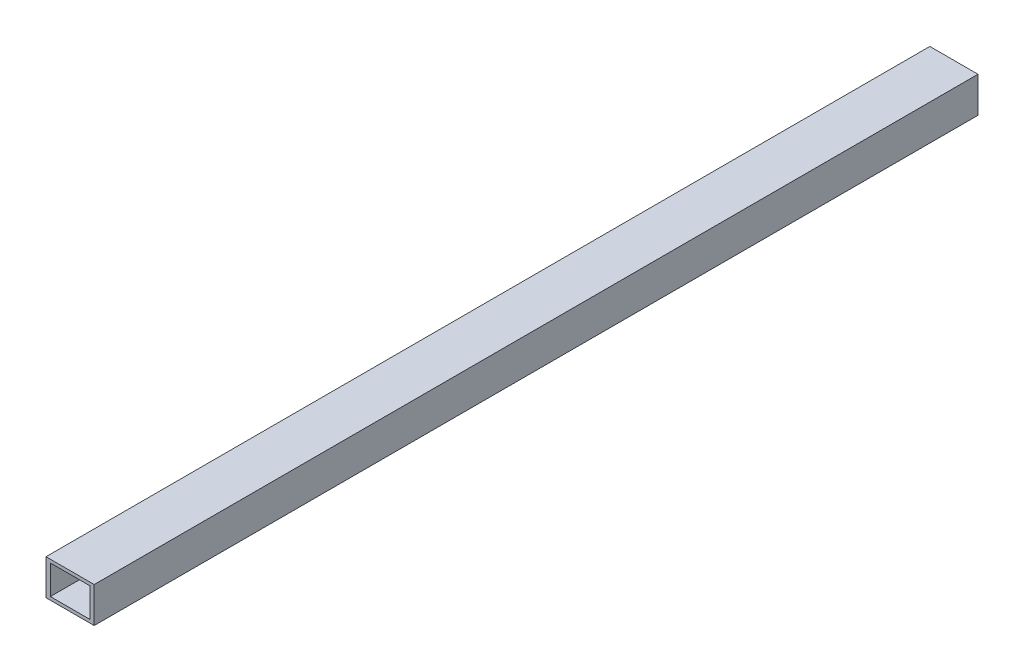
from build123d import *

# Parameters (mm, degrees)
SKIZZE1_W                       = 54.49683461
SKIZZE1_H                       = 40.231486728
SKIZZE1_W_2                     = 44.59591978
SKIZZE1_H_2                     = 32.922281956
AUFSATZ_LINEAR_AUSTRAGEN1_DEPTH = 500


with BuildPart() as part:
    # Skizze1 → Aufsatz-Linear austragen1 (new body, symmetric)
    with BuildSketch(Plane.XY):
        Rectangle(SKIZZE1_W, SKIZZE1_H)
        Rectangle(SKIZZE1_W_2, SKIZZE1_H_2, mode=Mode.SUBTRACT)
    extrude(amount=AUFSATZ_LINEAR_AUSTRAGEN1_DEPTH, both=True)


solid = part.part
